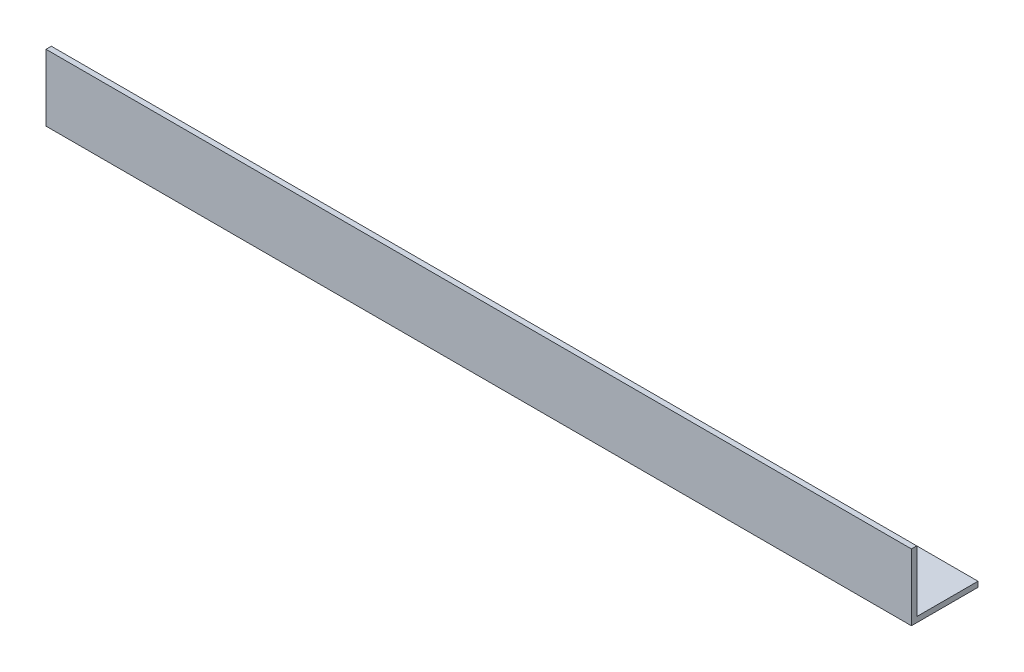
from build123d import *

# Parameters (mm, degrees)
EXTRUDE_1_DEPTH = 650


with BuildPart() as part:
    # Эскиз1 → Вытянуть-Тонкостенный1 (new body)
    with BuildSketch(Plane(origin=(0, 0, 0), x_dir=(0, 0, -1), z_dir=(1, 0, 0))):
        Polygon((0, 50), (0, 0), (50, 0), (50, 4), (4, 4), (4, 50), align=None)
    extrude(amount=EXTRUDE_1_DEPTH)


solid = part.part
